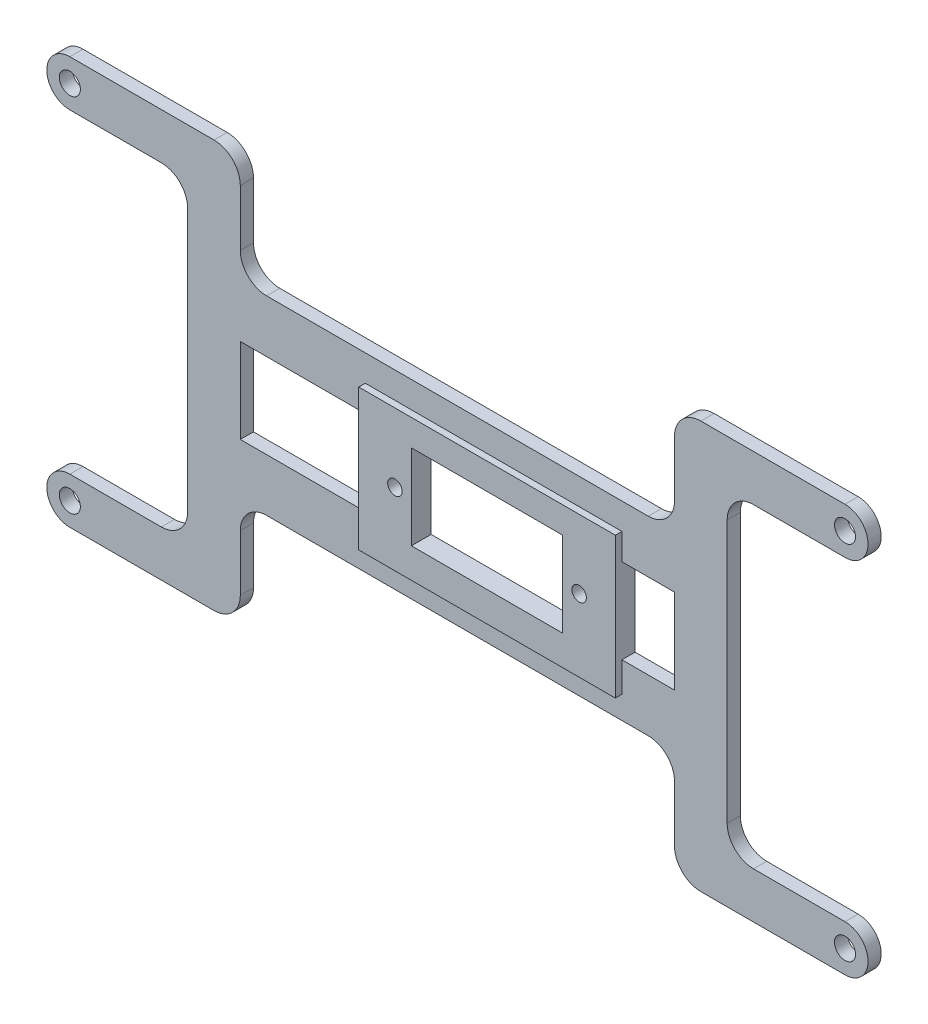
from build123d import *

# Parameters (mm, degrees)
SKETCH1_R                = 1.6
SKETCH1_R_2              = 2.1
BOSS_EXTRUDE3_DEPTH      = 2
BOSS_EXTRUDE4_DEPTH      = 2
SKETCH4_W                = 66
SKETCH4_H                = 16.340111315
SKETCH4_H_2              = 24.741581589
CUT_EXTRUDE3_DEPTH       = 14.5
FILLET1_R                = 4
SKETCH5_W                = 26
SKETCH5_H                = 27
SKETCH5_R                = 6
BOSS_EXTRUDE5_DEPTH      = 2
SKETCH6_W                = 5
SKETCH6_H                = 27
CUT_EXTRUDE4_DEPTH       = 14.5
SKETCH7_R                = 2.5
BOSS_EXTRUDE6_DEPTH      = 2
SKETCH8_R                = 2.5
CUT_EXTRUDE5_DEPTH       = 10
SKETCH9_W                = 22.081
SKETCH9_H                = 27
CUT_EXTRUDE6_DEPTH       = 10
CUT_EXTRUDE7_DEPTH       = 10
SKETCH11_W               = 28.061
SKETCH11_H               = 7.05
BOSS_EXTRUDE7_DEPTH      = 2
SKETCH12_W               = 44.061
SKETCH12_H               = 28.9
CUT_EXTRUDE9_DEPTH       = 10
BOSS_EXTRUDE9_DEPTH      = 2
FILLET2_R                = 4
SKETCH14_R               = 2.5
SKETCH14_W               = 28.061
SKETCH14_H               = 12.9
BOSS_EXTRUDE10_DEPTH     = 1
SKETCH15_W               = 3
SKETCH15_H               = 12.9
BOSS_EXTRUDE11_DEPTH     = 2.5
SKETCH16_W               = 3
SKETCH16_H               = 12.9
BOSS_EXTRUDE12_DEPTH     = 2.5
SKETCH17_W               = 6
SKETCH17_H               = 12.9
CUT_EXTRUDE12_DEPTH      = 5.5
BOSS_EXTRUDE13_DEPTH     = 3
CUT_EXTRUDE13_DEPTH      = 1
SKETCH21_W               = 0.081
SKETCH21_H               = 12.9
SKETCH21_W_2             = 4.98
CUT_EXTRUDE14_DEPTH      = 5.5
SKETCH22_R               = 2.5
BOSS_EXTRUDE14_DEPTH     = 3
SKETCH23_R               = 1.1
CUT_EXTRUDE17_DEPTH      = 5.5
CUT_EXTRUDE17_DEPTH_BACK = 5.5


with BuildPart() as part:
    # Sketch1 → Boss-Extrude3 (new body)
    with BuildSketch(Plane.XY):
        with BuildLine():
            Line((0, 3.5), (37.911912125, 3.5))
            Line((37.911912125, 3.5), (37.911912125, 13.97107578))
            Line((37.911912125, 13.97107578), (37.911912125, 40.97107578))
            Line((37.911912125, 40.97107578), (37.911912125, 51.44215156))
            Line((37.911912125, 51.44215156), (0, 51.44215156))
            ThreePointArc((0, 51.44215156), (-3.5, 54.94215156), (0, 58.44215156))
            Line((0, 58.44215156), (45.911912125, 58.44215156))
            Line((45.911912125, 58.44215156), (45.911912125, 51.44215156))
            Line((45.911912125, 51.44215156), (45.911912125, 48.97107578))
            Line((45.911912125, 48.97107578), (50.911912125, 48.97107578))
            Line((50.911912125, 48.97107578), (66.911912125, 48.97107578))
            Line((66.911912125, 48.97107578), (71.911912125, 48.97107578))
            Line((71.911912125, 48.97107578), (71.911912125, 51.44215156))
            Line((71.911912125, 51.44215156), (71.911912125, 58.44215156))
            Line((71.911912125, 58.44215156), (117.82382425, 58.44215156))
            ThreePointArc((117.82382425, 58.44215156), (121.32382425, 54.94215156), (117.82382425, 51.44215156))
            Line((117.82382425, 51.44215156), (79.911912125, 51.44215156))
            Line((79.911912125, 51.44215156), (79.911912125, 40.97107578))
            Line((79.911912125, 40.97107578), (79.911912125, 13.97107578))
            Line((79.911912125, 13.97107578), (79.911912125, 3.5))
            Line((79.911912125, 3.5), (117.82382425, 3.5))
            ThreePointArc((117.82382425, 3.5), (121.32382425, 0), (117.82382425, -3.5))
            Line((117.82382425, -3.5), (71.911912125, -3.5))
            Line((71.911912125, -3.5), (71.911912125, 3.5))
            Line((71.911912125, 3.5), (71.911912125, 5.97107578))
            Line((71.911912125, 5.97107578), (66.911912125, 5.97107578))
            Line((66.911912125, 5.97107578), (50.911912125, 5.97107578))
            Line((50.911912125, 5.97107578), (45.911912125, 5.97107578))
            Line((45.911912125, 5.97107578), (45.911912125, 3.5))
            Line((45.911912125, 3.5), (45.911912125, -3.5))
            Line((45.911912125, -3.5), (0, -3.5))
            ThreePointArc((0, -3.5), (-3.5, 0), (0, 3.5))
        make_face()
        with Locations((0, 54.94215156)):
            Circle(SKETCH1_R, mode=Mode.SUBTRACT)
        with Locations((117.82382425, 54.94215156)):
            Circle(SKETCH1_R, mode=Mode.SUBTRACT)
        with Locations((117.82382425, 0)):
            Circle(SKETCH1_R, mode=Mode.SUBTRACT)
        Circle(SKETCH1_R, mode=Mode.SUBTRACT)
        with Locations((66.911912125, 44.97107578)):
            Circle(SKETCH1_R_2, mode=Mode.SUBTRACT)
        with Locations((66.911912125, 9.97107578)):
            Circle(SKETCH1_R_2, mode=Mode.SUBTRACT)
        with Locations((50.911912125, 9.97107578)):
            Circle(SKETCH1_R_2, mode=Mode.SUBTRACT)
        with Locations((50.911912125, 44.97107578)):
            Circle(SKETCH1_R_2, mode=Mode.SUBTRACT)
        Polygon((66.911912125, 40.97107578), (50.911912125, 40.97107578), (45.911912125, 40.97107578), (45.911912125, 27.47107578), (45.911912125, 13.97107578), (50.911912125, 13.97107578), (66.911912125, 13.97107578), (71.911912125, 13.97107578), (71.911912125, 27.47107578), (71.911912125, 40.97107578), align=None, mode=Mode.SUBTRACT)
    extrude(amount=BOSS_EXTRUDE3_DEPTH)

    # Sketch3 → Boss-Extrude4 (add)
    with BuildSketch(Plane.XY.offset(2)):
        Polygon((71.911912125, 13.97107578), (99.911912125, 13.97107578), (99.911912125, 3.5), (91.911912125, 3.5), (91.911912125, 5.97107578), (71.911912125, 5.97107578), align=None)
        Polygon((91.911912125, 51.44215156), (99.911912125, 51.44215156), (99.911912125, 40.97107578), (71.911912125, 40.97107578), (71.911912125, 48.97107578), (91.911912125, 48.97107578), align=None)
        Polygon((45.911912125, 40.97107578), (17.911912125, 40.97107578), (17.911912125, 51.44215156), (25.911912125, 51.44215156), (25.911912125, 48.97107578), (45.911912125, 48.97107578), align=None)
        Polygon((25.911912125, 3.5), (17.911912125, 3.5), (17.911912125, 13.97107578), (45.911912125, 13.97107578), (45.911912125, 5.97107578), (25.911912125, 5.97107578), align=None)
    extrude(amount=-BOSS_EXTRUDE4_DEPTH)

    # Sketch4 → Cut-Extrude3 (cut)
    with BuildSketch(Plane.XY.offset(2)):
        with Locations((58.911912125, 57.141131438)):
            Rectangle(SKETCH4_W, SKETCH4_H)
        with Locations((58.911912125, -6.399715014)):
            Rectangle(SKETCH4_W, SKETCH4_H_2)
    extrude(amount=-CUT_EXTRUDE3_DEPTH, mode=Mode.SUBTRACT)

    # Fillet1
    fillet1_edges = [part.edges().sort_by_distance(p)[0] for p in [
        (99.911912125, 13.97107578, 1),
        (99.911912125, 3.5, 1),
        (91.911912125, 5.97107578, 1),
        (91.911912125, 48.97107578, 1),
        (99.911912125, 51.44215156, 1),
        (99.911912125, 40.97107578, 1),
        (17.911912125, 40.97107578, 1),
        (17.911912125, 51.44215156, 1),
        (25.911912125, 48.97107578, 1),
        (25.911912125, 5.97107578, 1),
        (17.911912125, 3.5, 1),
        (17.911912125, 13.97107578, 1),
        (91.911912125, 58.44215156, 1),
        (25.911912125, 58.44215156, 1),
        (91.911912125, -3.5, 1),
        (25.911912125, -3.5, 1),
    ]]
    fillet(fillet1_edges, radius=FILLET1_R)

    # Sketch5 → Boss-Extrude5 (add)
    with BuildSketch(Plane.XY.offset(2)):
        with Locations((58.911912125, 27.47107578)):
            Rectangle(SKETCH5_W, SKETCH5_H)
        with Locations((58.911912125, 27.47107578)):
            Circle(SKETCH5_R, mode=Mode.SUBTRACT)
    extrude(amount=-BOSS_EXTRUDE5_DEPTH)

    # Sketch6 → Cut-Extrude4 (cut)
    with BuildSketch(Plane.XY.offset(2)):
        with Locations((40.411912125, 27.47107578)):
            Rectangle(SKETCH6_W, SKETCH6_H)
        with Locations((77.411912125, 27.47107578)):
            Rectangle(SKETCH6_W, SKETCH6_H)
    extrude(amount=-CUT_EXTRUDE4_DEPTH, mode=Mode.SUBTRACT)

    # Sketch7 → Boss-Extrude6 (add)
    with BuildSketch(Plane.XY.offset(2)):
        Polygon((80.891912125, 27.47107578), (80.891912125, 40.97107578), (88.891912125, 40.97107578), (88.891912125, 27.47107578), (88.891912125, 13.97107578), (80.891912125, 13.97107578), align=None)
        with Locations((84.891912125, 27.47107578)):
            Circle(SKETCH7_R, mode=Mode.SUBTRACT)
    extrude(amount=-BOSS_EXTRUDE6_DEPTH)

    # Sketch8 → Cut-Extrude5 (cut)
    with BuildSketch(Plane.XY.offset(2)):
        with Locations((48.830912125, 27.47107578)):
            Circle(SKETCH8_R)
    extrude(amount=-CUT_EXTRUDE5_DEPTH, mode=Mode.SUBTRACT)

    # Sketch9 → Cut-Extrude6 (cut)
    with BuildSketch(Plane.XY.offset(2)):
        Polygon((42.911912125, 40.97107578), (44.830912125, 40.97107578), (44.830912125, 27.47107578), (44.830912125, 13.97107578), (42.911912125, 13.97107578), align=None)
        with Locations((63.871412125, 27.47107578)):
            Rectangle(SKETCH9_W, SKETCH9_H)
    extrude(amount=-CUT_EXTRUDE6_DEPTH, mode=Mode.SUBTRACT)

    # Sketch10 → Cut-Extrude7 (cut)
    with BuildSketch(Plane.XY.offset(2)):
        Polygon((44.830912125, 13.97107578), (44.830912125, 13.02107578), (88.891912125, 13.02107578), (88.891912125, 13.97107578), (106.020559472, 13.97107578), (106.020559472, 3.5), (12.964535502, 3.5), (12.964535502, 13.97107578), align=None)
        Polygon((88.891912125, 40.97107578), (88.891912125, 41.92107578), (44.830912125, 41.92107578), (44.830912125, 40.97107578), (12.964535502, 40.97107578), (12.964535502, 51.44215156), (106.020559472, 51.44215156), (106.020559472, 40.97107578), align=None)
    extrude(amount=-CUT_EXTRUDE7_DEPTH, mode=Mode.SUBTRACT)

    # Sketch11 → Boss-Extrude7 (add)
    with BuildSketch(Plane.XY.offset(2)):
        with Locations((66.861412125, 37.44607578)):
            Rectangle(SKETCH11_W, SKETCH11_H)
        with Locations((66.861412125, 17.49607578)):
            Rectangle(SKETCH11_W, SKETCH11_H)
    extrude(amount=-BOSS_EXTRUDE7_DEPTH)

    # Sketch12 → Cut-Extrude9 (cut)
    with BuildSketch(Plane.XY.offset(2)):
        Polygon((25.911912125, 1.23553789), (25.911912125, 54.44215156), (91.911912125, 54.44215156), (91.911912125, 0.5), align=None)
        with Locations((66.861412125, 27.47107578)):
            Rectangle(SKETCH12_W, SKETCH12_H, mode=Mode.SUBTRACT)
    extrude(amount=-CUT_EXTRUDE9_DEPTH, mode=Mode.SUBTRACT)

    # Sketch13 → Boss-Extrude9 (add)
    with BuildSketch(Plane.XY.offset(2)):
        Polygon((17.911912125, 3.5), (25.911912125, 3.5), (25.911912125, 13.02107578), (44.830912125, 13.02107578), (44.830912125, 21.02107578), (25.911912125, 21.02107578), (25.911912125, 33.92107578), (44.830912125, 33.92107578), (44.830912125, 41.92107578), (25.911912125, 41.92107578), (25.911912125, 51.44215156), (17.911912125, 51.44215156), (17.911912125, 13.02107578), align=None)
        Polygon((99.911912125, 51.44215156), (91.911912125, 51.44215156), (91.911912125, 41.92107578), (88.891912125, 41.92107578), (88.891912125, 33.92107578), (91.911912125, 33.92107578), (91.911912125, 21.02107578), (88.891912125, 21.02107578), (88.891912125, 13.02107578), (91.911912125, 13.02107578), (91.911912125, 3.5), (99.911912125, 3.5), (99.911912125, 41.92107578), align=None)
    extrude(amount=-BOSS_EXTRUDE9_DEPTH)

    # Fillet2
    fillet2_edges = [part.edges().sort_by_distance(p)[0] for p in [
        (99.911912125, 51.44215156, 1),
        (99.911912125, 3.5, 1),
        (91.911912125, 13.02107578, 1),
        (91.911912125, 41.92107578, 1),
        (25.911912125, 13.02107578, 1),
        (17.911912125, 3.5, 1),
        (17.911912125, 51.44215156, 1),
        (25.911912125, 41.92107578, 1),
    ]]
    fillet(fillet2_edges, radius=FILLET2_R)

    # Sketch14 → Boss-Extrude10 (add)
    with BuildSketch(Plane.XY.offset(2)):
        Polygon((44.830912125, 33.92107578), (44.830912125, 37.92107578), (88.891912125, 37.92107578), (88.891912125, 33.92107578), (88.891912125, 21.02107578), (88.891912125, 16.479152283), (44.830912125, 16.479152283), (44.830912125, 21.02107578), align=None)
        with Locations((48.830912125, 27.47107578)):
            Circle(SKETCH14_R, mode=Mode.SUBTRACT)
        with Locations((84.891912125, 27.47107578)):
            Circle(SKETCH14_R, mode=Mode.SUBTRACT)
        with Locations((66.861412125, 27.47107578)):
            Rectangle(SKETCH14_W, SKETCH14_H, mode=Mode.SUBTRACT)
    extrude(amount=BOSS_EXTRUDE10_DEPTH)

    # Sketch15 → Boss-Extrude11 (add)
    with BuildSketch(Plane(origin=(52.830912125, 0, 0), x_dir=(0, 0, -1), z_dir=(1, 0, 0))):
        with Locations((-1.5, 27.47107578)):
            Rectangle(SKETCH15_W, SKETCH15_H)
    extrude(amount=BOSS_EXTRUDE11_DEPTH)

    # Sketch16 → Boss-Extrude12 (add)
    with BuildSketch(Plane.ZY.offset(-80.891912125)):
        with Locations((1.5, 27.47107578)):
            Rectangle(SKETCH16_W, SKETCH16_H)
    extrude(amount=BOSS_EXTRUDE12_DEPTH)

    # Sketch17 → Cut-Extrude12 (cut)
    with BuildSketch(Plane.XY.offset(3)):
        with Locations((55.911912125, 27.47107578)):
            Rectangle(SKETCH17_W, SKETCH17_H)
    extrude(amount=-CUT_EXTRUDE12_DEPTH, mode=Mode.SUBTRACT)

    # Sketch19 → Boss-Extrude13 (add)
    with BuildSketch(Plane.XY.offset(3)):
        Polygon((75.911912125, 27.47107578), (75.911912125, 33.92107578), (78.391912125, 33.92107578), (78.391912125, 21.02107578), (75.911912125, 21.02107578), align=None)
    extrude(amount=-BOSS_EXTRUDE13_DEPTH)

    # Sketch20 → Cut-Extrude13 (cut)
    with BuildSketch(Plane.XY.offset(3)):
        Polygon((37.503218373, 44.973204348), (36.040097649, -4.597325781), (97.140019083, -2.256332623), (103.870374413, 35.726281372), (82.918485646, 46.904523704), align=None)
        Polygon((83.911912125, 27.47107578), (83.911912125, 37.92107578), (44.911912125, 37.92107578), (44.911912125, 27.47107578), (44.911912125, 16.479152283), (83.911912125, 16.479152283), align=None, mode=Mode.SUBTRACT)
    extrude(amount=-CUT_EXTRUDE13_DEPTH, mode=Mode.SUBTRACT)

    # Sketch21 → Cut-Extrude14 (cut)
    with BuildSketch(Plane.XY.offset(2)):
        with Locations((44.871412125, 27.47107578)):
            Rectangle(SKETCH21_W, SKETCH21_H)
        with Locations((86.401912125, 27.47107578)):
            Rectangle(SKETCH21_W_2, SKETCH21_H)
    extrude(amount=-CUT_EXTRUDE14_DEPTH, mode=Mode.SUBTRACT)

    # Sketch22 → Boss-Extrude14 (add)
    with BuildSketch(Plane.XY.offset(3)):
        with Locations((48.830912125, 27.47107578)):
            Circle(SKETCH22_R)
        Polygon((83.911912125, 25.171162738), (83.911912125, 29.770988822), (78.292126648, 33.292249077), (79.181354054, 24.086130054), align=None)
    extrude(amount=-BOSS_EXTRUDE14_DEPTH)

    # Sketch23 → Cut-Extrude17 (cut, two sides)
    with BuildSketch(Plane.XY.offset(2)) as cut_extrude17_sk:
        with Locations((50.411912125, 27.47107578)):
            Circle(SKETCH23_R)
        with Locations((78.411912125, 27.47107578)):
            Circle(SKETCH23_R)
    extrude(amount=CUT_EXTRUDE17_DEPTH, mode=Mode.SUBTRACT)
    extrude(cut_extrude17_sk.sketch, amount=-CUT_EXTRUDE17_DEPTH_BACK, mode=Mode.SUBTRACT)


solid = part.part
